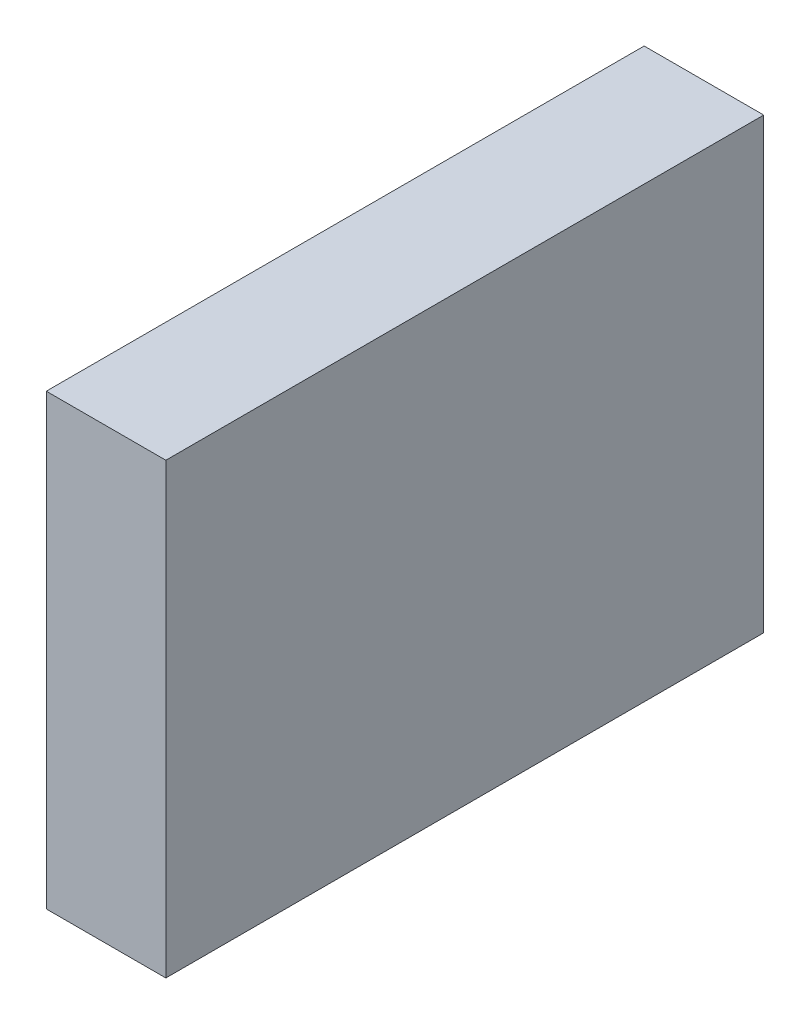
from build123d import *

# Parameters (mm, degrees)
SKETCH1_W           = 40
SKETCH1_H           = 200
BOSS_EXTRUDE1_DEPTH = 150


with BuildPart() as part:
    # Sketch1 → Boss-Extrude1 (new body)
    with BuildSketch(Plane(origin=(0, 0, 0), x_dir=(1, 0, 0), z_dir=(0, 1, 0))):
        Rectangle(SKETCH1_W, SKETCH1_H)
    extrude(amount=BOSS_EXTRUDE1_DEPTH)


solid = part.part
